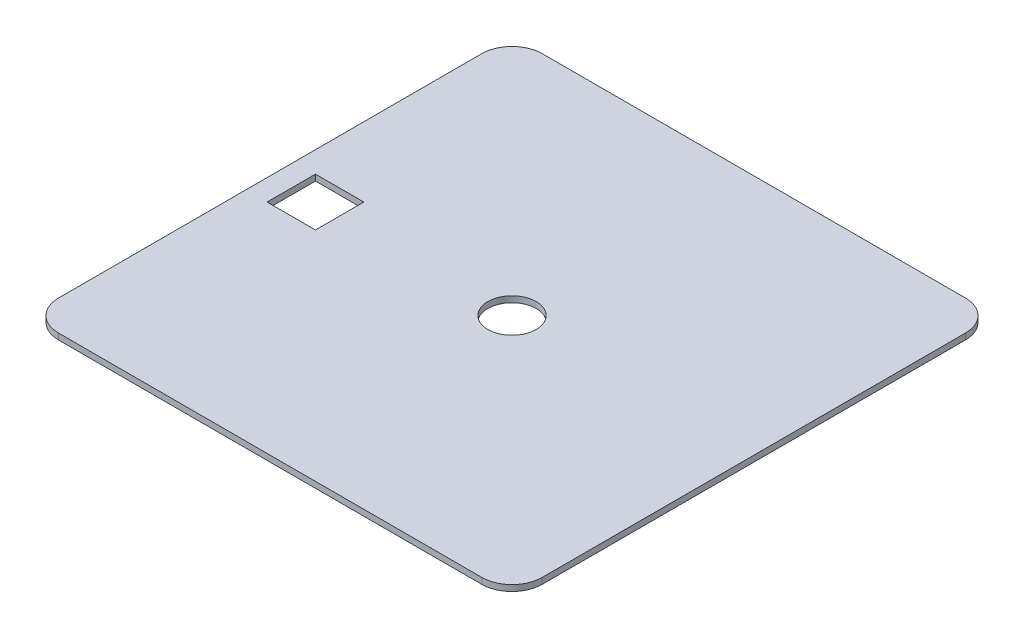
from build123d import *

# Parameters (mm, degrees)
ESQUISSE1_W             = 80
ESQUISSE1_H             = 80
EXTRUSION1_DEPTH        = 1
CONG_1_R                = 5
ESQUISSE3_R             = 4
ENL_V_MAT_EXTRU_1_DEPTH = 2
ESQUISSE4_W             = 8
ESQUISSE4_H             = 8
ENL_V_MAT_EXTRU_2_DEPTH = 2


with BuildPart() as part:
    # Esquisse1 → Extrusion1 (new body)
    with BuildSketch(Plane(origin=(0, 0, 0), x_dir=(1, 0, 0), z_dir=(0, 1, 0))):
        with Locations((40, 40)):
            Rectangle(ESQUISSE1_W, ESQUISSE1_H)
    extrude(amount=EXTRUSION1_DEPTH)

    # Congé1
    cong_1_edges = [part.edges().sort_by_distance(p)[0] for p in [
        (0, 0.5, -80),
        (80, 0.5, -80),
        (80, 0.5, 0),
        (0, 0.5, 0),
    ]]
    fillet(cong_1_edges, radius=CONG_1_R)

    # Esquisse3 → Enlèv. mat.-Extru.1 (cut, through all)
    with BuildSketch(Plane(origin=(0, 1, 0), x_dir=(1, 0, 0), z_dir=(0, 1, 0))):
        with Locations((40, 40)):
            Circle(ESQUISSE3_R)
    extrude(amount=-ENL_V_MAT_EXTRU_1_DEPTH, mode=Mode.SUBTRACT)

    # Esquisse4 → Enlèv. mat.-Extru.2 (cut, through all)
    with BuildSketch(Plane(origin=(0, 1, 0), x_dir=(1, 0, 0), z_dir=(0, 1, 0))):
        with Locations((7.5, 40)):
            Rectangle(ESQUISSE4_W, ESQUISSE4_H)
    extrude(amount=-ENL_V_MAT_EXTRU_2_DEPTH, mode=Mode.SUBTRACT)


solid = part.part
